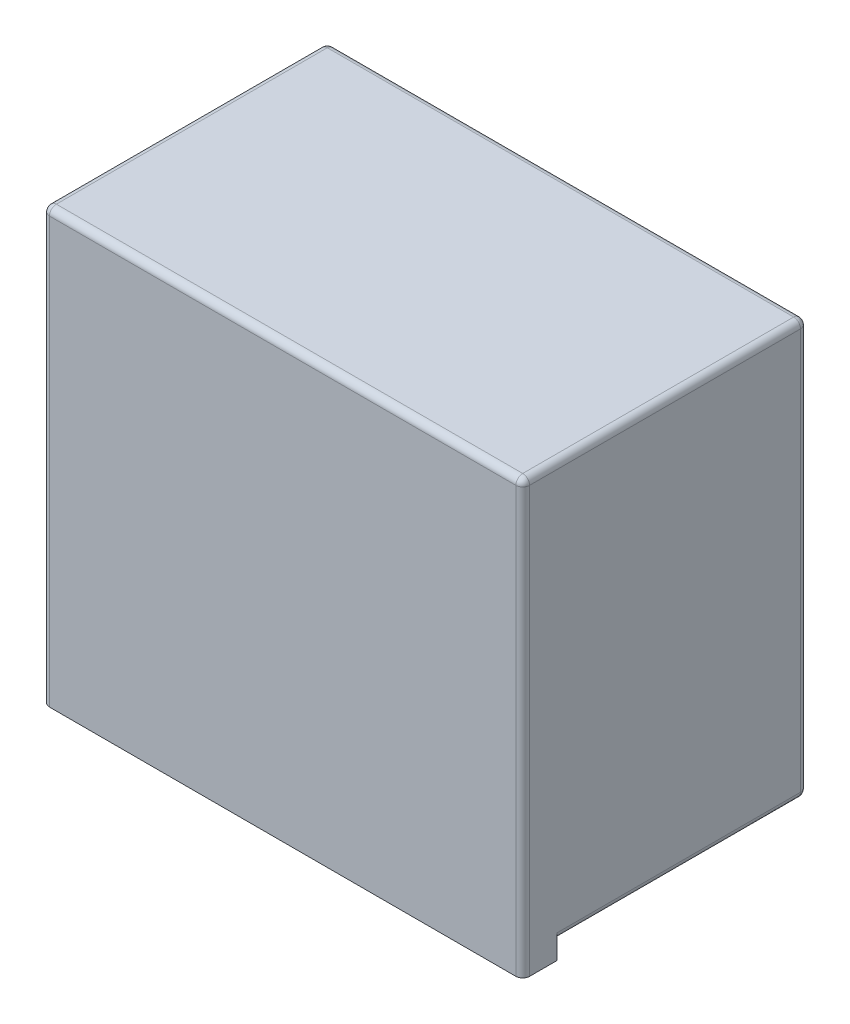
from build123d import *

# Parameters (mm, degrees)
CROQUIS1_W            = 14
CROQUIS1_H            = 12.6
EXTRUIR1_DEPTH        = 8.3
CROQUIS2_R            = 4.75
CORTAR_EXTRUIR1_DEPTH = 7.3
REDONDEO1_R           = 0.5
CROQUIS3_W            = 9.2
CROQUIS3_H            = 0.789398471
CROQUIS3_W_2          = 2.03522765
CROQUIS3_W_3          = 1.728148887
CROQUIS3_H_2          = 1.147657029
CORTAR_EXTRUIR2_DEPTH = 7.3
REDONDEO2_R           = 0.5
EXTRUIR2_DEPTH        = 7.3
CROQUIS5_W            = 1.5
CROQUIS5_H            = 2.2
CROQUIS5_R            = 0.3
CORTAR_EXTRUIR3_DEPTH = 7.3
CHAFL_N1_SIZE         = 0.4
REDONDEO3_R           = 0.2


with BuildPart() as part:
    # Croquis1 → Extruir1 (new body)
    with BuildSketch(Plane.XY):
        with Locations((7, 6.3)):
            Rectangle(CROQUIS1_W, CROQUIS1_H)
    extrude(amount=EXTRUIR1_DEPTH)

    # Croquis2 → Cortar-Extruir1 (cut)
    with BuildSketch(Plane(origin=(0, 0, 0), x_dir=(-1, 0, 0), z_dir=(0, 0, -1))):
        with Locations((-7, 6.15)):
            Circle(CROQUIS2_R)
    extrude(amount=-CORTAR_EXTRUIR1_DEPTH, mode=Mode.SUBTRACT)

    # Redondeo1
    redondeo1_edges = [part.edges().sort_by_distance(p)[0] for p in [
        (11.75, 6.15, 0),
    ]]
    fillet(redondeo1_edges, radius=REDONDEO1_R)

    # Croquis3 → Cortar-Extruir2 (cut)
    with BuildSketch(Plane(origin=(0, 0, 0), x_dir=(-1, 0, 0), z_dir=(0, 0, -1))):
        with Locations((-7, 0.105300765)):
            Rectangle(CROQUIS3_W, CROQUIS3_H)
        with Locations((0.017613825, 0.105300765)):
            Rectangle(CROQUIS3_W_2, CROQUIS3_H)
        with Locations((-13.864074444, -0.073828514)):
            Rectangle(CROQUIS3_W_3, CROQUIS3_H_2)
    extrude(amount=-CORTAR_EXTRUIR2_DEPTH, mode=Mode.SUBTRACT)

    # Redondeo2
    redondeo2_edges = [part.edges().sort_by_distance(p)[0] for p in [
        (1.7, 0, 0),
        (12.3, 0, 0),
    ]]
    fillet(redondeo2_edges, radius=REDONDEO2_R)

    # Redondeo3
    redondeo3_edges = [part.edges().sort_by_distance(p)[0] for p in [
        (14, 6.3, 8.3),
        (7, 12.6, 8.3),
        (0.5, 0.5, 0),
        (0, 0.5, 3.65),
        (0, 6.3, 8.3),
        (7, 0.5, 0),
        (7, 12.6, 0),
        (14, 6.55, 0),
        (0, 6.55, 0),
        (13.5, 0.5, 0),
        (14, 0.5, 3.65),
        (0, 12.6, 4.15),
        (14, 12.6, 4.15),
    ]]
    fillet(redondeo3_edges, radius=REDONDEO3_R)


with BuildPart() as body_2:
    # Croquis4 → Extruir2 (new body)
    with BuildSketch(Plane(origin=(0, 0, 0), x_dir=(-1, 0, 0), z_dir=(0, 0, -1))):
        with BuildLine():
            Line((-10.524202037, 4.6), (-9.35, 4.6))
            Line((-9.35, 4.6), (-9.35, 3.100409864))
            ThreePointArc((-9.35, 3.100409864), (-7, 2.3), (-4.65, 3.100409864))
            Line((-4.65, 3.100409864), (-4.65, 4.6))
            Line((-4.65, 4.6), (-3.475797963, 4.6))
            ThreePointArc((-3.475797963, 4.6), (-3.550620396, 7.860052733), (-6.1, 9.893327397))
            Line((-6.1, 9.893327397), (-6.1, 9.3))
            Line((-6.1, 9.3), (-7.9, 9.3))
            Line((-7.9, 9.3), (-7.9, 9.893327397))
            ThreePointArc((-7.9, 9.893327397), (-10.449379604, 7.860052733), (-10.524202037, 4.6))
        make_face()
    extrude(amount=-EXTRUIR2_DEPTH)

    # Croquis5 → Cortar-Extruir3 (cut)
    with BuildSketch(Plane(origin=(0, 0, 0), x_dir=(-1, 0, 0), z_dir=(0, 0, -1))):
        with Locations((-7, 7.4)):
            Rectangle(CROQUIS5_W, CROQUIS5_H)
        with Locations((-4.671319375, 8.001728149)):
            Circle(CROQUIS5_R)
        with Locations((-4.261881024, 5.775407112)):
            Circle(CROQUIS5_R)
        with Locations((-9.328680625, 8.001728149)):
            Circle(CROQUIS5_R)
        with Locations((-9.738118976, 5.775407112)):
            Circle(CROQUIS5_R)
        with Locations((-8.228315055, 3.753805251)):
            Circle(CROQUIS5_R)
        with Locations((-5.771684945, 3.753805251)):
            Circle(CROQUIS5_R)
    extrude(amount=-CORTAR_EXTRUIR3_DEPTH, mode=Mode.SUBTRACT)

    # Chaflán1
    chafl_n1_edges = [body_2.edges().sort_by_distance(p)[0] for p in [
        (4.971319375, 8.001728149, 0),
        (4.561881024, 5.775407112, 0),
        (9.628680625, 8.001728149, 0),
        (10.038118976, 5.775407112, 0),
        (8.528315055, 3.753805251, 0),
        (6.071684945, 3.753805251, 0),
    ]]
    chamfer(chafl_n1_edges, length=CHAFL_N1_SIZE)


solid = Compound([part.part, body_2.part])
